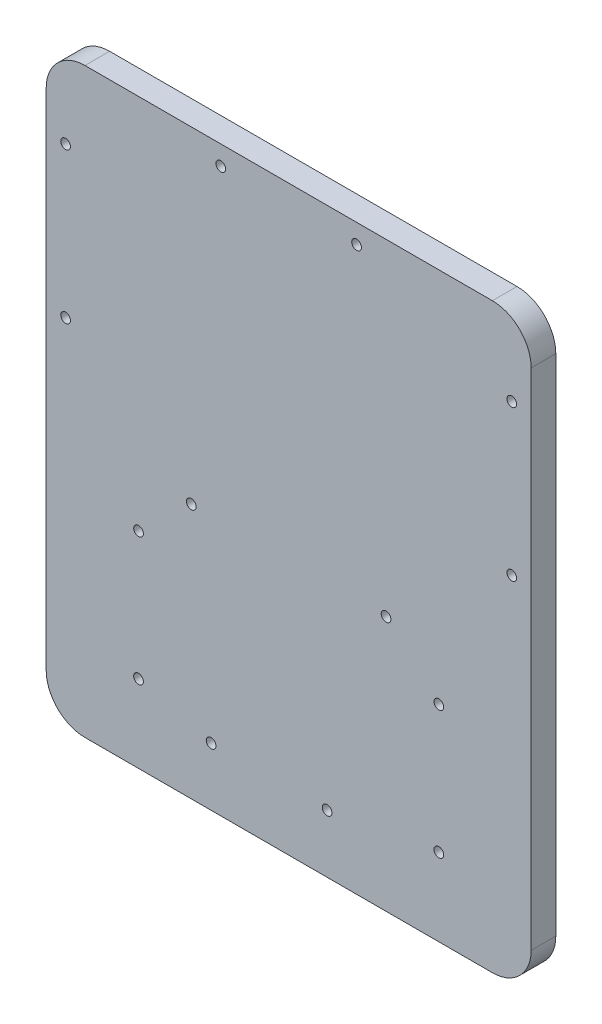
from build123d import *

# Parameters (mm, degrees)
SKETCH1_W           = 125
SKETCH1_H           = 150
SKETCH1_R           = 1.25
BOSS_EXTRUDE1_DEPTH = 6.35
FILLET1_R           = 10
CUT_EXTRUDE1_REACH  = 8.35
SKETCH2_R           = 1.25


with BuildPart() as part:
    # Sketch1 → Boss-Extrude1 (new body)
    with BuildSketch(Plane.XY):
        Rectangle(SKETCH1_W, SKETCH1_H)
        with Locations((-25.1, -9.2)):
            Circle(SKETCH1_R, mode=Mode.SUBTRACT)
        with Locations((25.1, -9.2)):
            Circle(SKETCH1_R, mode=Mode.SUBTRACT)
        with Locations((-20, -60)):
            Circle(SKETCH1_R, mode=Mode.SUBTRACT)
        with Locations((9.9, -60)):
            Circle(SKETCH1_R, mode=Mode.SUBTRACT)
        with Locations((-17.5, 70)):
            Circle(SKETCH1_R, mode=Mode.SUBTRACT)
        with Locations((17.5, 70)):
            Circle(SKETCH1_R, mode=Mode.SUBTRACT)
        with Locations((38.7, -55)):
            Circle(SKETCH1_R, mode=Mode.SUBTRACT)
        with Locations((38.7, -22)):
            Circle(SKETCH1_R, mode=Mode.SUBTRACT)
        with Locations((-38.7, -22)):
            Circle(SKETCH1_R, mode=Mode.SUBTRACT)
        with Locations((-38.7, -55)):
            Circle(SKETCH1_R, mode=Mode.SUBTRACT)
    extrude(amount=BOSS_EXTRUDE1_DEPTH)

    # Fillet1
    fillet1_edges = [part.edges().sort_by_distance(p)[0] for p in [
        (62.5, -75, 3.175),
        (-62.5, -75, 3.175),
        (-62.5, 75, 3.175),
        (62.5, 75, 3.175),
    ]]
    fillet(fillet1_edges, radius=FILLET1_R)

    # Sketch2 → Cut-Extrude1 (cut, up to next)
    with BuildSketch(Plane.XY.offset(6.35), mode=Mode.PRIVATE) as cut_extrude1_sk1:
        with Locations((57.5, 55)):
            Circle(SKETCH2_R)
    cut_extrude1_tool1 = extrude(cut_extrude1_sk1.sketch, amount=-CUT_EXTRUDE1_REACH, mode=Mode.PRIVATE) & part.part
    add(cut_extrude1_tool1.solids().sort_by_distance((57.5, 55, 6.35))[0], mode=Mode.SUBTRACT)
    # Sketch2 → Cut-Extrude1 (cut, up to next)
    with BuildSketch(Plane.XY.offset(6.35), mode=Mode.PRIVATE) as cut_extrude1_sk2:
        with Locations((57.5, 16.2)):
            Circle(SKETCH2_R)
    cut_extrude1_tool2 = extrude(cut_extrude1_sk2.sketch, amount=-CUT_EXTRUDE1_REACH, mode=Mode.PRIVATE) & part.part
    add(cut_extrude1_tool2.solids().sort_by_distance((57.5, 16.2, 6.35))[0], mode=Mode.SUBTRACT)
    # Sketch2 → Cut-Extrude1 (cut, up to next)
    with BuildSketch(Plane.XY.offset(6.35), mode=Mode.PRIVATE) as cut_extrude1_sk3:
        with Locations((-57.5, 16.2)):
            Circle(SKETCH2_R)
    cut_extrude1_tool3 = extrude(cut_extrude1_sk3.sketch, amount=-CUT_EXTRUDE1_REACH, mode=Mode.PRIVATE) & part.part
    add(cut_extrude1_tool3.solids().sort_by_distance((-57.5, 16.2, 6.35))[0], mode=Mode.SUBTRACT)
    # Sketch2 → Cut-Extrude1 (cut, up to next)
    with BuildSketch(Plane.XY.offset(6.35), mode=Mode.PRIVATE) as cut_extrude1_sk4:
        with Locations((-57.5, 55)):
            Circle(SKETCH2_R)
    cut_extrude1_tool4 = extrude(cut_extrude1_sk4.sketch, amount=-CUT_EXTRUDE1_REACH, mode=Mode.PRIVATE) & part.part
    add(cut_extrude1_tool4.solids().sort_by_distance((-57.5, 55, 6.35))[0], mode=Mode.SUBTRACT)


solid = part.part
